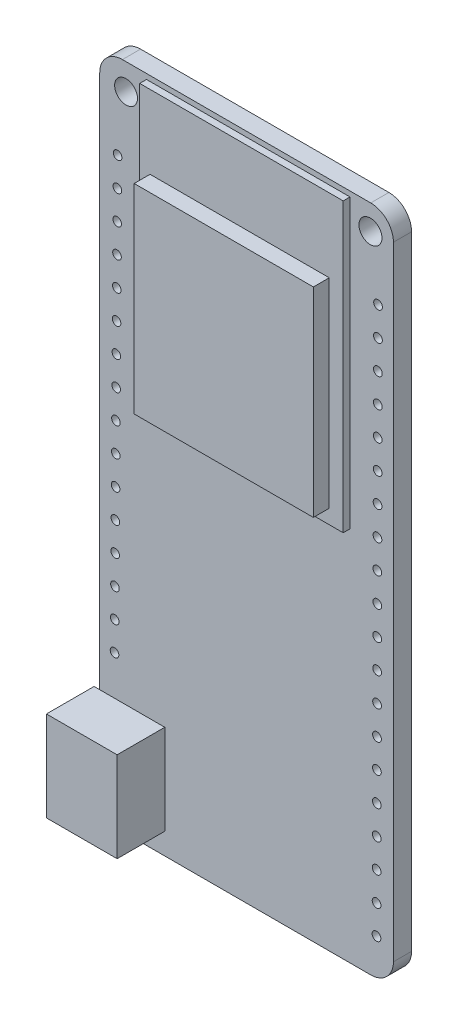
from build123d import *

# Parameters (mm, degrees)
ESQUISSE3_W             = 15.791637012
ESQUISSE3_H             = 17.590684267
BOSS_EXTRU_1_DEPTH      = 2
ESQUISSE2_W             = 17.933359934
ESQUISSE2_H             = 25.329443091
BOSS_EXTRU_2_DEPTH      = 0.6
ESQUISSE4_W             = 6.231089561
ESQUISSE4_H             = 7.934254041
BOSS_EXTRU_3_DEPTH      = 4.2
ESQUISSE5_W             = 3.122951255
ESQUISSE5_H             = 6.687685859
ENL_V_MAT_EXTRU_1_DEPTH = 4.2
ESQUISSE1_R             = 1.007769755
ESQUISSE1_R_2           = 1.015003651
ESQUISSE1_R_3           = 0.379085232
ESQUISSE1_R_4           = 0.384809787
BOSS_EXTRU_5_DEPTH      = 1.6


with BuildPart() as part:
    # Esquisse3 → Boss.-Extru.1 (new body)
    with BuildSketch(Plane.XY):
        with Locations((22.462662563, 538.851133679)):
            Rectangle(ESQUISSE3_W, ESQUISSE3_H)
    extrude(amount=BOSS_EXTRU_1_DEPTH)

    # Esquisse2 → Boss.-Extru.2 (add)
    with BuildSketch(Plane.XY):
        with Locations((22.619722244, 541.464035644)):
            Rectangle(ESQUISSE2_W, ESQUISSE2_H)
    extrude(amount=BOSS_EXTRU_2_DEPTH)



with BuildPart() as body_2:
    # Esquisse4 → Boss.-Extru.3 (new body)
    with BuildSketch(Plane.XY):
        with Locations((12.149458307, 501.526955697)):
            Rectangle(ESQUISSE4_W, ESQUISSE4_H)
    extrude(amount=BOSS_EXTRU_3_DEPTH)

    # Esquisse5 → Enlèv. mat.-Extru.1 (cut)
    with BuildSketch(Plane.ZY.offset(-9.033913526)):
        with Locations((2.075345186, 501.536635321)):
            Rectangle(ESQUISSE5_W, ESQUISSE5_H)
    extrude(amount=-ENL_V_MAT_EXTRU_1_DEPTH, mode=Mode.SUBTRACT)


with BuildPart() as part_1:
    add(part.part)

    add(body_2.part)  # Boss.-Extru.5 merges body 2
    # Esquisse1 → Boss.-Extru.5 (add)
    with BuildSketch(Plane.XY):
        with BuildLine():
            Line((11.53160478, 495.667835537), (33.413782108, 495.667835537))
            ThreePointArc((33.413782108, 495.667835537), (34.82799567, 496.253621975), (35.413782108, 497.667835537))
            Line((35.413782108, 497.667835537), (35.413782108, 552.585869124))
            ThreePointArc((35.413782108, 552.585869124), (34.82799567, 554.000082687), (33.413782108, 554.585869124))
            Line((33.413782108, 554.585869124), (11.53160478, 554.585869124))
            ThreePointArc((11.53160478, 554.585869124), (10.117391217, 554.000082687), (9.53160478, 552.585869124))
            Line((9.53160478, 552.585869124), (9.53160478, 497.667835537))
            ThreePointArc((9.53160478, 497.667835537), (10.117391217, 496.253621975), (11.53160478, 495.667835537))
        make_face()
        with Locations((11.851858825, 552.281521948)):
            Circle(ESQUISSE1_R, mode=Mode.SUBTRACT)
        with Locations((33.388345227, 552.400453993)):
            Circle(ESQUISSE1_R_2, mode=Mode.SUBTRACT)
        with Locations((11.106340619, 547.074143577)):
            Circle(ESQUISSE1_R_3, mode=Mode.SUBTRACT)
        with Locations((11.088253425, 544.534207977)):
            Circle(ESQUISSE1_R_3, mode=Mode.SUBTRACT)
        with Locations((11.070166231, 541.994272377)):
            Circle(ESQUISSE1_R_3, mode=Mode.SUBTRACT)
        with Locations((11.052079036, 539.454336777)):
            Circle(ESQUISSE1_R_3, mode=Mode.SUBTRACT)
        with Locations((11.033991842, 536.914401176)):
            Circle(ESQUISSE1_R_3, mode=Mode.SUBTRACT)
        with Locations((11.015904648, 534.374465576)):
            Circle(ESQUISSE1_R_3, mode=Mode.SUBTRACT)
        with Locations((10.997817454, 531.834529976)):
            Circle(ESQUISSE1_R_3, mode=Mode.SUBTRACT)
        with Locations((10.979730259, 529.294594376)):
            Circle(ESQUISSE1_R_3, mode=Mode.SUBTRACT)
        with Locations((10.961643065, 526.754658775)):
            Circle(ESQUISSE1_R_3, mode=Mode.SUBTRACT)
        with Locations((10.943555871, 524.214723175)):
            Circle(ESQUISSE1_R_3, mode=Mode.SUBTRACT)
        with Locations((10.925468676, 521.674787575)):
            Circle(ESQUISSE1_R_3, mode=Mode.SUBTRACT)
        with Locations((10.907381482, 519.134851975)):
            Circle(ESQUISSE1_R_3, mode=Mode.SUBTRACT)
        with Locations((10.889294288, 516.594916374)):
            Circle(ESQUISSE1_R_3, mode=Mode.SUBTRACT)
        with Locations((10.871207093, 514.054980774)):
            Circle(ESQUISSE1_R_3, mode=Mode.SUBTRACT)
        with Locations((10.853119899, 511.515045174)):
            Circle(ESQUISSE1_R_3, mode=Mode.SUBTRACT)
        with Locations((10.835032705, 508.975109574)):
            Circle(ESQUISSE1_R_3, mode=Mode.SUBTRACT)
        with Locations((34.05821266, 547.138652956)):
            Circle(ESQUISSE1_R_4, mode=Mode.SUBTRACT)
        with Locations((34.051054062, 544.598663044)):
            Circle(ESQUISSE1_R_4, mode=Mode.SUBTRACT)
        with Locations((34.043895464, 542.058673131)):
            Circle(ESQUISSE1_R_4, mode=Mode.SUBTRACT)
        with Locations((34.036736867, 539.518683219)):
            Circle(ESQUISSE1_R_4, mode=Mode.SUBTRACT)
        with Locations((34.029578269, 536.978693307)):
            Circle(ESQUISSE1_R_4, mode=Mode.SUBTRACT)
        with Locations((34.022419671, 534.438703395)):
            Circle(ESQUISSE1_R_4, mode=Mode.SUBTRACT)
        with Locations((34.015261074, 531.898713482)):
            Circle(ESQUISSE1_R_4, mode=Mode.SUBTRACT)
        with Locations((34.008102476, 529.35872357)):
            Circle(ESQUISSE1_R_4, mode=Mode.SUBTRACT)
        with Locations((34.000943878, 526.818733658)):
            Circle(ESQUISSE1_R_4, mode=Mode.SUBTRACT)
        with Locations((33.993785281, 524.278743745)):
            Circle(ESQUISSE1_R_4, mode=Mode.SUBTRACT)
        with Locations((33.986626683, 521.738753833)):
            Circle(ESQUISSE1_R_4, mode=Mode.SUBTRACT)
        with Locations((33.979468085, 519.198763921)):
            Circle(ESQUISSE1_R_4, mode=Mode.SUBTRACT)
        with Locations((33.972309488, 516.658774009)):
            Circle(ESQUISSE1_R_4, mode=Mode.SUBTRACT)
        with Locations((33.96515089, 514.118784096)):
            Circle(ESQUISSE1_R_4, mode=Mode.SUBTRACT)
        with Locations((33.957992292, 511.578794184)):
            Circle(ESQUISSE1_R_4, mode=Mode.SUBTRACT)
        with Locations((33.950833695, 509.038804272)):
            Circle(ESQUISSE1_R_4, mode=Mode.SUBTRACT)
        with Locations((33.943675097, 506.498814359)):
            Circle(ESQUISSE1_R_4, mode=Mode.SUBTRACT)
        with Locations((33.9365165, 503.958824447)):
            Circle(ESQUISSE1_R_4, mode=Mode.SUBTRACT)
        with Locations((33.929357902, 501.418834535)):
            Circle(ESQUISSE1_R_4, mode=Mode.SUBTRACT)
        with Locations((33.922199304, 498.878844623)):
            Circle(ESQUISSE1_R_4, mode=Mode.SUBTRACT)
    extrude(amount=-BOSS_EXTRU_5_DEPTH)


solid = part_1.part
